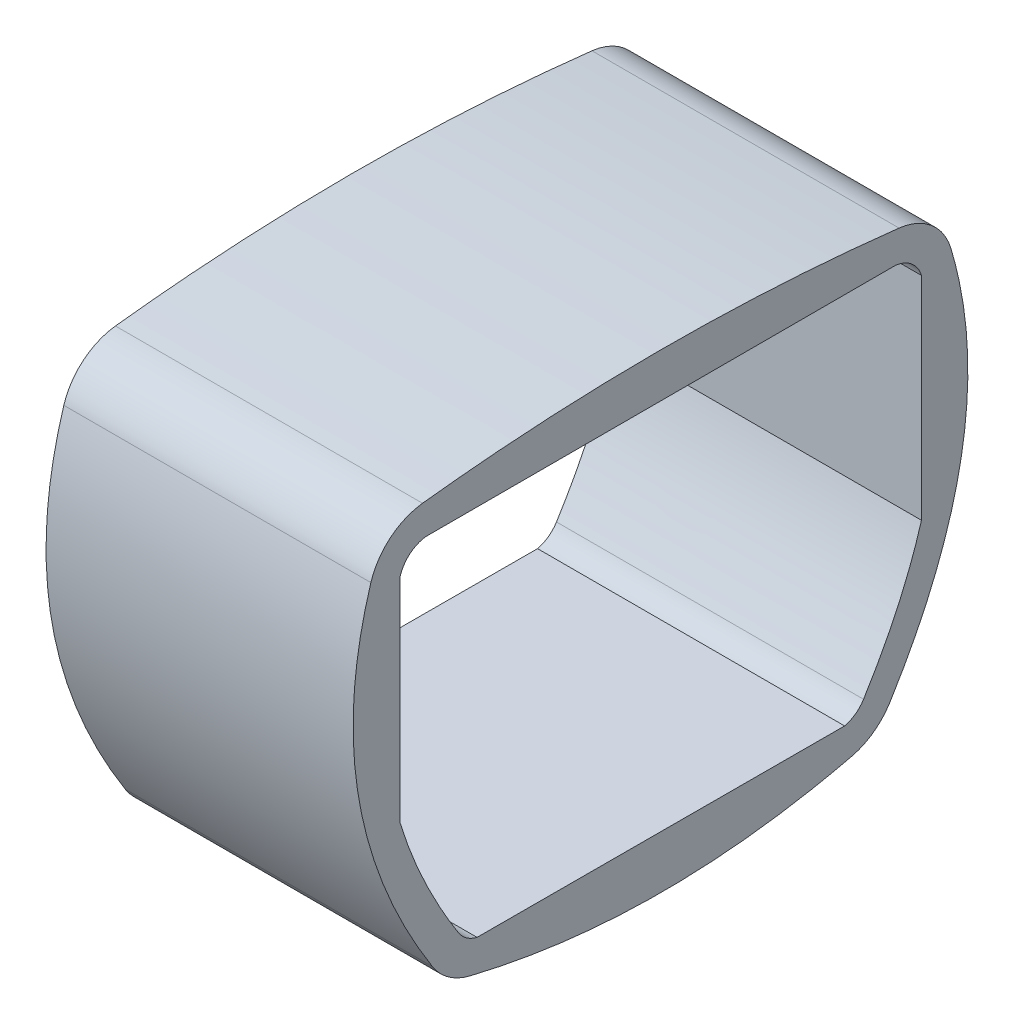
from build123d import *

# Parameters (mm, degrees)
BOSS_EXTRUDE8_DEPTH = 127
FILLET4_R           = 25.4
FILLET5_R           = 25.4
FILLET6_R           = 25.4
FILLET7_R           = 25.4
CUT_EXTRUDE3_DEPTH  = 127


with BuildPart() as part:
    # Sketch8 → Boss-Extrude8 (new body)
    with BuildSketch(Plane(origin=(0, 0, 0), x_dir=(0, 0, -1), z_dir=(1, 0, 0))):
        with BuildLine():
            add(Edge.make_bspline(
                [(-89.517321988, -36.735442624), (-0.634104952, -60.975176902), (88.282437318, -37.028001665)],
                knots=[0, 0, 0, 1, 1, 1], degree=2))
            add(Edge.make_bspline(
                [(113.698608464, 137.87777005), (148.206005145, 51.814722278), (88.282437318, -37.028001665)],
                knots=[0, 0, 0, 1, 1, 1], degree=2))
            add(Edge.make_bspline(
                [(-114.901391536, 137.87777005), (-0.596034429, 153.168104446), (113.698608464, 137.87777005)],
                knots=[0, 0, 0, 1, 1, 1], degree=2))
            add(Edge.make_bspline(
                [(-114.901391536, 137.87777005), (-150.307927624, 52.141383045), (-89.517321988, -36.735442624)],
                knots=[0, 0, 0, 1, 1, 1], degree=2))
        make_face()
    extrude(amount=BOSS_EXTRUDE8_DEPTH)

    # Fillet4
    fillet4_edges = [part.edges().sort_by_distance(p)[0] for p in [
        (63.5, 137.87777005, 114.901391536),
    ]]
    fillet(fillet4_edges, radius=FILLET4_R)

    # Fillet5
    fillet5_edges = [part.edges().sort_by_distance(p)[0] for p in [
        (63.5, -36.735442624, 89.517321988),
    ]]
    fillet(fillet5_edges, radius=FILLET5_R)

    # Fillet6
    fillet6_edges = [part.edges().sort_by_distance(p)[0] for p in [
        (63.5, -37.028001665, -88.282437318),
    ]]
    fillet(fillet6_edges, radius=FILLET6_R)

    # Fillet7
    fillet7_edges = [part.edges().sort_by_distance(p)[0] for p in [
        (63.5, 137.87777005, -113.698608464),
    ]]
    fillet(fillet7_edges, radius=FILLET7_R)

    # Sketch11 → Cut-Extrude3 (cut)
    with BuildSketch(Plane(origin=(127, 0, 0), x_dir=(0, 0, -1), z_dir=(1, 0, 0))):
        with BuildLine():
            Line((-97.784453692, 127.212925067), (96.404571612, 127.233510211))
            ThreePointArc((96.404571612, 127.233510211), (103.111414071, 124.347995488), (107.121047874, 118.246293452))
            Line((107.121047874, 118.246293452), (107.121047874, 30.555919475))
            add(Edge.make_bspline(
                [(83.170467652, -21.57810628), (86.415391697, -16.370968411), (89.460079781, -11.083046595), (95.101033744, -0.326289829), (97.697391853, 5.142507912), (102.383358499, 16.284548341), (104.473090716, 21.95774113), (106.563539535, 28.680710784), (106.846143616, 29.616761907), (107.121047874, 30.555919475)],
                knots=[0, 0, 0, 0, 0.125, 0.125, 0.25, 0.25, 0.375, 0.375, 0.395143119, 0.395143119, 0.395143119, 0.395143119], degree=3))
            ThreePointArc((83.170467652, -21.57810628), (79.812495261, -25.167952265), (75.342856961, -27.213754366))
            Line((75.342856961, -27.213754366), (-76.690566802, -26.92748329))
            ThreePointArc((-76.690566802, -26.92748329), (-81.098266675, -24.904774618), (-84.426415504, -21.377368501))
            add(Edge.make_bspline(
                [(-108.462610917, 29.857145517), (-108.303396788, 29.330392074), (-108.141581554, 28.804173566), (-107.065329258, 25.36262207), (-106.073914954, 22.462725348), (-103.939463914, 16.695703597), (-102.803256231, 13.846836717), (-99.203580144, 5.396186106), (-96.549578269, -0.10990853), (-90.803206271, -10.901941939), (-87.710677179, -16.187800874), (-84.426415504, -21.377368501)],
                knots=[0.613732154, 0.613732154, 0.613732154, 0.613732154, 0.625, 0.625, 0.6875, 0.6875, 0.75, 0.75, 0.875, 0.875, 1, 1, 1, 1], degree=3))
            Line((-108.462610917, 29.857145517), (-108.462610917, 118.343948745))
            ThreePointArc((-108.462610917, 118.343948745), (-104.442431913, 124.366378611), (-97.784453692, 127.212925067))
        make_face()
    extrude(amount=-CUT_EXTRUDE3_DEPTH, mode=Mode.SUBTRACT)


solid = part.part
